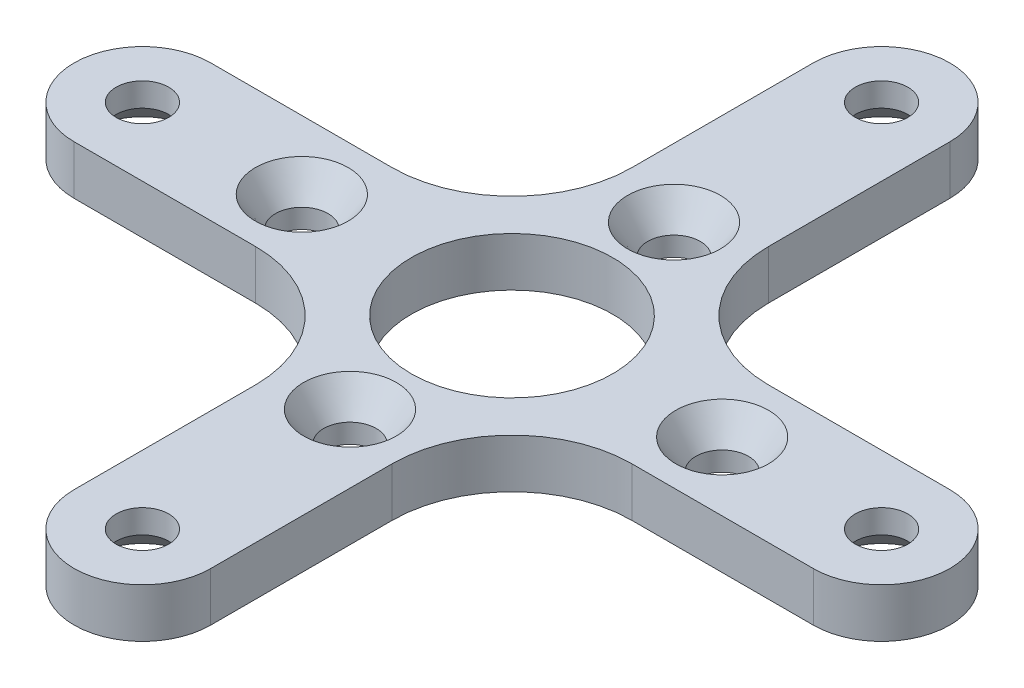
from build123d import *

# Parameters (mm, degrees)
SKETCH1_R           = 5.75
SKETCH1_R_2         = 1.5
BOSS_EXTRUDE1_DEPTH = 1.4
CHAMFER1_SIZE       = 1.45
CHAMFER2_SIZE       = 1.15
CHAMFER2_SIZE2      = 1.7


with BuildPart() as part:
    # Sketch1 → Boss-Extrude1 (new body, symmetric)
    with BuildSketch(Plane(origin=(0, 0, 0), x_dir=(1, 0, 0), z_dir=(0, 1, 0))):
        with BuildLine():
            Line((-21.1, 3.9), (-10.743250353, 3.9))
            ThreePointArc((-10.743250353, 3.9), (-5.904341623, 5.904341623), (-3.9, 10.743250353))
            Line((-3.9, 10.743250353), (-3.9, 21.1))
            ThreePointArc((-3.9, 21.1), (0, 25), (3.9, 21.1))
            Line((3.9, 21.1), (3.9, 10.743250353))
            ThreePointArc((3.9, 10.743250353), (5.904341623, 5.904341623), (10.743250353, 3.9))
            Line((10.743250353, 3.9), (21.1, 3.9))
            ThreePointArc((21.1, 3.9), (25, 0), (21.1, -3.9))
            Line((21.1, -3.9), (10.743250353, -3.9))
            ThreePointArc((10.743250353, -3.9), (5.904341623, -5.904341623), (3.9, -10.743250353))
            Line((3.9, -10.743250353), (3.9, -21.1))
            ThreePointArc((3.9, -21.1), (0, -25), (-3.9, -21.1))
            Line((-3.9, -21.1), (-3.9, -10.743250353))
            ThreePointArc((-3.9, -10.743250353), (-5.904341623, -5.904341623), (-10.743250353, -3.9))
            Line((-10.743250353, -3.9), (-21.1, -3.9))
            ThreePointArc((-21.1, -3.9), (-25, 0), (-21.1, 3.9))
        make_face()
        Circle(SKETCH1_R, mode=Mode.SUBTRACT)
        with Locations((0, 9.25)):
            Circle(SKETCH1_R_2, mode=Mode.SUBTRACT)
        with Locations((0, 21.1)):
            Circle(SKETCH1_R_2, mode=Mode.SUBTRACT)
        with Locations((12, 0)):
            Circle(SKETCH1_R_2, mode=Mode.SUBTRACT)
        with Locations((21.1, 0)):
            Circle(SKETCH1_R_2, mode=Mode.SUBTRACT)
        with Locations((0, -9.25)):
            Circle(SKETCH1_R_2, mode=Mode.SUBTRACT)
        with Locations((0, -21.1)):
            Circle(SKETCH1_R_2, mode=Mode.SUBTRACT)
        with Locations((-12, 0)):
            Circle(SKETCH1_R_2, mode=Mode.SUBTRACT)
        with Locations((-21.1, 0)):
            Circle(SKETCH1_R_2, mode=Mode.SUBTRACT)
    extrude(amount=BOSS_EXTRUDE1_DEPTH, both=True)

    # Chamfer1
    chamfer1_edges = [part.edges().sort_by_distance(p)[0] for p in [
        (-1.5, -1.4, -21.1),
        (19.6, -1.4, 0),
        (-1.5, -1.4, 21.1),
        (-22.6, -1.4, 0),
    ]]
    chamfer(chamfer1_edges, length=CHAMFER1_SIZE)

    # Chamfer2
    chamfer2_edges = [part.edges().sort_by_distance(p)[0] for p in [
        (-1.5, 1.4, -9.25),
        (10.5, 1.4, 0),
        (-1.5, 1.4, 9.25),
        (-13.5, 1.4, 0),
    ]]
    chamfer2_side = [part.faces().sort_by_distance(p)[0] for p in [
        (5.404341623, 1.4, 5.404341623),
    ]]
    chamfer(chamfer2_edges, length=CHAMFER2_SIZE, length2=CHAMFER2_SIZE2, reference=chamfer2_side[0])


solid = part.part
